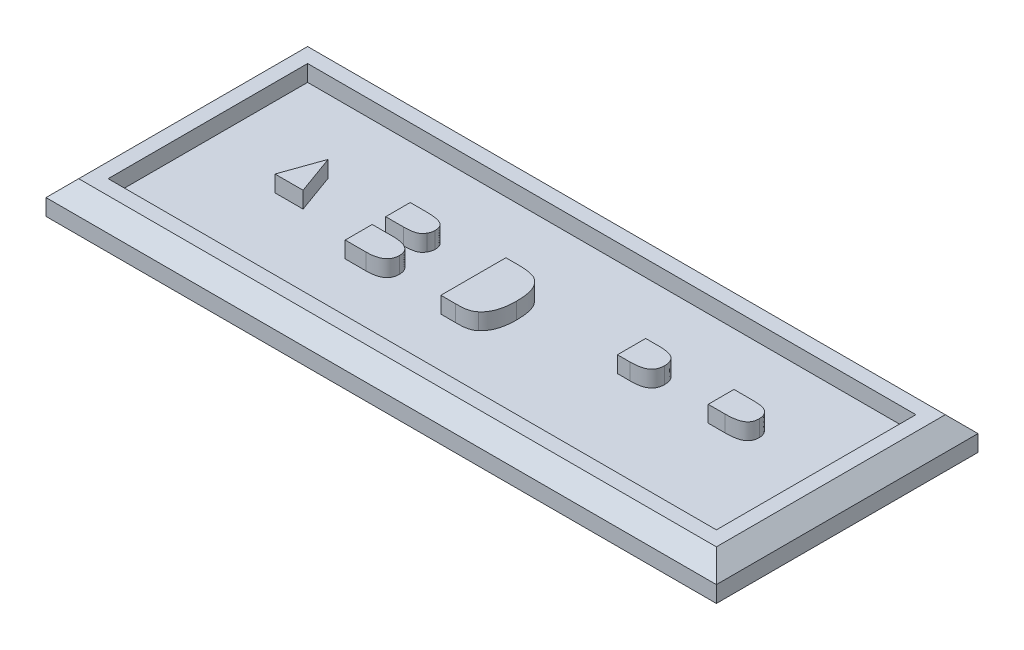
from build123d import *

# Parameters (mm, degrees)
SKETCH1_W           = 41
SKETCH1_H           = 16
BOSS_EXTRUDE1_DEPTH = 2
CHAMFER1_SIZE       = 1
SKETCH2_W           = 37.2
SKETCH2_H           = 12.2
CUT_EXTRUDE1_DEPTH  = 1
BOSS_EXTRUDE2_DEPTH = 0.1
BOSS_EXTRUDE3_DEPTH = 1
SKETCH6_W           = 37.2
SKETCH6_H           = 12.2
CUT_EXTRUDE2_DEPTH  = 1


with BuildPart() as part:
    # Sketch1 → Boss-Extrude1 (new body)
    with BuildSketch(Plane(origin=(0, 0, 0), x_dir=(1, 0, 0), z_dir=(0, 1, 0))):
        Rectangle(SKETCH1_W, SKETCH1_H)
    extrude(amount=BOSS_EXTRUDE1_DEPTH)

    # Chamfer1
    chamfer1_edges = [part.edges().sort_by_distance(p)[0] for p in [
        (20.5, 2, 0),
        (0, 2, -8),
        (-20.5, 2, 0),
        (0, 2, 8),
    ]]
    chamfer(chamfer1_edges, length=CHAMFER1_SIZE)

    # Sketch2 → Cut-Extrude1 (cut)
    with BuildSketch(Plane(origin=(0, 2, 0), x_dir=(1, 0, 0), z_dir=(0, 1, 0))):
        Rectangle(SKETCH2_W, SKETCH2_H)
    extrude(amount=-CUT_EXTRUDE1_DEPTH, mode=Mode.SUBTRACT)

    # Sketch3 → Boss-Extrude2 (add)
    with BuildSketch(Plane(origin=(0, 1, 0), x_dir=(1, 0, 0), z_dir=(0, 1, 0))):
        with BuildLine():
            Line((-11.441015625, -2.349609375), (-11.715234375, -1.65))
            Line((-11.715234375, -1.65), (-14.0484375, -1.65))
            Line((-14.0484375, -1.65), (-14.32265625, -2.36484375))
            add(Edge.make_bspline(
                [(-14.32265625, -2.36484375), (-14.347835962, -2.429152255), (-14.393986303, -2.547019345), (-14.465517251, -2.705100133), (-14.530354862, -2.829674932), (-14.59047857, -2.926424451), (-14.660607879, -2.997756493), (-14.748545347, -3.043456515), (-14.853497882, -3.070371804), (-14.929116363, -3.073387981), (-14.96953125, -3.075)],
                knots=[0, 0, 0, 0, 0.000207167, 0.000379703, 0.000520191, 0.000628424, 0.000720406, 0.000816364, 0.00092182, 0.001042887, 0.001042887, 0.001042887, 0.001042887], degree=3))
            add(Edge.make_bspline(
                [(-14.96953125, -3.075), (-15.005312309, -3.072983598), (-15.075874133, -3.069007165), (-15.177866168, -3.036727284), (-15.273080921, -2.985249355), (-15.359460508, -2.915667549), (-15.432410746, -2.833500255), (-15.485274497, -2.742148574), (-15.519177587, -2.645309748), (-15.52305102, -2.578005721), (-15.525, -2.544140625)],
                knots=[0, 0, 0, 0, 0.000107161, 0.000211326, 0.00031776, 0.000430315, 0.00054243, 0.000645342, 0.000745398, 0.00084673, 0.00084673, 0.00084673, 0.00084673], degree=3))
            add(Edge.make_bspline(
                [(-15.525, -2.544140625), (-15.523193689, -2.503741289), (-15.519483191, -2.420753523), (-15.493089704, -2.316105591), (-15.461401167, -2.225629232), (-15.432122251, -2.143573309), (-15.397345548, -2.048738896), (-15.370506217, -1.981956896), (-15.35625, -1.946484375)],
                knots=[0, 0, 0, 0, 0.000121067, 0.000248693, 0.000321699, 0.000408804, 0.000510028, 0.00062471, 0.00062471, 0.00062471, 0.00062471], degree=3))
            Line((-15.35625, -1.946484375), (-13.887890625, 1.82109375))
            add(Edge.make_bspline(
                [(-13.887890625, 1.82109375), (-13.877033183, 1.849640427), (-13.854390814, 1.909172349), (-13.81718647, 2.002041188), (-13.779422608, 2.103716802), (-13.737887875, 2.210452438), (-13.695622927, 2.317352773), (-13.648036449, 2.416388897), (-13.602120299, 2.507310579), (-13.552270206, 2.588270224), (-13.49796298, 2.661372403), (-13.43572884, 2.725938743), (-13.3651987, 2.782594974), (-13.287981265, 2.833809847), (-13.200946539, 2.874891932), (-13.104314819, 2.90434525), (-12.998298587, 2.921934285), (-12.924288276, 2.923953619), (-12.8859375, 2.925)],
                knots=[0, 0, 0, 0, 9.1624e-05, 0.000191075, 0.000300116, 0.00041698, 0.000534712, 0.000644799, 0.000746483, 0.000840145, 0.000929676, 0.001019185, 0.001108317, 0.001200627, 0.001296557, 0.001395897, 0.00150282, 0.001617813, 0.001617813, 0.001617813, 0.001617813], degree=3))
            add(Edge.make_bspline(
                [(-12.8859375, 2.925), (-12.847191426, 2.923964252), (-12.772395624, 2.921964834), (-12.665292553, 2.904219346), (-12.567931136, 2.875501695), (-12.481665511, 2.833299239), (-12.403893228, 2.783573977), (-12.333122677, 2.727829245), (-12.271563961, 2.663396877), (-12.200252444, 2.568895574), (-12.123532789, 2.440826658), (-12.059347002, 2.302613175), (-12.012806287, 2.180972039), (-11.969275082, 2.076734824), (-11.924501628, 1.957068728), (-11.892603014, 1.87264561), (-11.87578125, 1.828125)],
                knots=[0, 0, 0, 0, 0.000116163, 0.000224243, 0.000324704, 0.000419575, 0.000511251, 0.000601295, 0.000689147, 0.000777745, 0.000956013, 0.001135834, 0.001234194, 0.001346701, 0.001474671, 0.001617453, 0.001617453, 0.001617453, 0.001617453], degree=3))
            Line((-11.87578125, 1.828125), (-10.37578125, -1.91484375))
            add(Edge.make_bspline(
                [(-10.37578125, -1.91484375), (-10.362069188, -1.94919831), (-10.335664466, -2.015353397), (-10.298319026, -2.110858221), (-10.270475505, -2.200435562), (-10.242779562, -2.281190367), (-10.225096723, -2.35601766), (-10.210418027, -2.422642639), (-10.201346416, -2.482167939), (-10.200431427, -2.519504684), (-10.2, -2.537109375)],
                knots=[0, 0, 0, 0, 0.000110982, 0.000213714, 0.000307471, 0.000392341, 0.000469649, 0.00053791, 0.000597075, 0.000649862, 0.000649862, 0.000649862, 0.000649862], degree=3))
            add(Edge.make_bspline(
                [(-10.2, -2.537109375), (-10.202155142, -2.570132184), (-10.206480473, -2.636408348), (-10.238168464, -2.733668106), (-10.293183658, -2.82468516), (-10.364464071, -2.910029077), (-10.450232948, -2.983212519), (-10.54839153, -3.036396381), (-10.654957368, -3.069176662), (-10.729456816, -3.07304225), (-10.7671875, -3.075)],
                knots=[0, 0, 0, 0, 9.9001e-05, 0.000198693, 0.000303207, 0.00041634, 0.000531124, 0.000639146, 0.000749259, 0.000862252, 0.000862252, 0.000862252, 0.000862252], degree=3))
            add(Edge.make_bspline(
                [(-10.7671875, -3.075), (-10.810045817, -3.073116816), (-10.890793668, -3.069568774), (-11.002453245, -3.033539946), (-11.093956784, -2.974673834), (-11.15863903, -2.911722548), (-11.203137979, -2.848941962), (-11.238148472, -2.791272681), (-11.274323764, -2.723100446), (-11.322497594, -2.62112411), (-11.37672123, -2.494818059), (-11.420622538, -2.395667095), (-11.441015625, -2.349609375)],
                knots=[0, 0, 0, 0, 0.000128271, 0.000241671, 0.000347009, 0.00045225, 0.000510148, 0.000577477, 0.000654545, 0.000741556, 0.000915752, 0.001066865, 0.001066865, 0.001066865, 0.001066865], degree=3))
        make_face()
        Polygon((-13.74375, -0.75), (-12.028125, -0.75), (-12.894140625, 1.65), align=None, mode=Mode.SUBTRACT)
        with BuildLine():
            Line((-6.75703125, -3), (-8.5171875, -3))
            add(Edge.make_bspline(
                [(-8.5171875, -3), (-8.548066158, -2.999684683), (-8.607211026, -2.999080726), (-8.692644647, -2.990770966), (-8.770947545, -2.976754729), (-8.842771247, -2.958217792), (-8.908089191, -2.93471954), (-8.96692833, -2.9061107), (-9.017782509, -2.869904795), (-9.07875055, -2.816360555), (-9.140301939, -2.729140438), (-9.189624937, -2.601657903), (-9.219877565, -2.450216486), (-9.223214212, -2.341173041), (-9.225, -2.2828125)],
                knots=[0, 0, 0, 0, 9.2608e-05, 0.000177381, 0.000257146, 0.000331048, 0.00039963, 0.00046514, 0.000526583, 0.000586337, 0.000707992, 0.000842042, 0.000993957, 0.001168885, 0.001168885, 0.001168885, 0.001168885], degree=3))
            Line((-9.225, -2.2828125), (-9.225, 2.0578125))
            add(Edge.make_bspline(
                [(-9.225, 2.0578125), (-9.223375416, 2.117371055), (-9.220355101, 2.228098226), (-9.188552092, 2.381042192), (-9.138305638, 2.508895247), (-9.062752389, 2.611877256), (-8.960932817, 2.687796753), (-8.834312538, 2.738830555), (-8.683927793, 2.770066267), (-8.575170639, 2.773284318), (-8.5171875, 2.775)],
                knots=[0, 0, 0, 0, 0.000178437, 0.000331738, 0.000466233, 0.00058764, 0.000709751, 0.000842085, 0.000994239, 0.001167997, 0.001167997, 0.001167997, 0.001167997], degree=3))
            Line((-8.5171875, 2.775), (-6.6515625, 2.775))
            add(Edge.make_bspline(
                [(-6.6515625, 2.775), (-6.585147608, 2.774247249), (-6.456546362, 2.772789674), (-6.270794249, 2.763868156), (-6.098739867, 2.74744078), (-5.939206601, 2.724758831), (-5.790298563, 2.691685935), (-5.649474707, 2.649197945), (-5.517714172, 2.591062773), (-5.435171158, 2.544064871), (-5.394140625, 2.520703125)],
                knots=[0, 0, 0, 0, 0.00019925, 0.000385814, 0.000557692, 0.000717622, 0.00086888, 0.001014918, 0.00115818, 0.001299778, 0.001299778, 0.001299778, 0.001299778], degree=3))
            add(Edge.make_bspline(
                [(-5.394140625, 2.520703125), (-5.360161211, 2.499396475), (-5.29220561, 2.456785199), (-5.197222519, 2.382645993), (-5.108971786, 2.299601488), (-5.026233579, 2.210306513), (-4.95099385, 2.114129902), (-4.885128336, 2.012316969), (-4.83023231, 1.904654916), (-4.783065612, 1.793232088), (-4.745153453, 1.677770503), (-4.720148205, 1.558227489), (-4.702342929, 1.436082227), (-4.701045751, 1.353191284), (-4.700390625, 1.311328125)],
                knots=[0, 0, 0, 0, 0.000120264, 0.000240517, 0.000360741, 0.000483481, 0.000605379, 0.000726627, 0.000846651, 0.000967445, 0.001089371, 0.001210505, 0.00133348, 0.001458958, 0.001458958, 0.001458958, 0.001458958], degree=3))
            add(Edge.make_bspline(
                [(-4.700390625, 1.311328125), (-4.702988671, 1.240796002), (-4.708044042, 1.103552116), (-4.750406113, 0.905273758), (-4.818338805, 0.720970725), (-4.915852756, 0.551862405), (-5.040552639, 0.397345857), (-5.194337126, 0.260072678), (-5.37373492, 0.13565648), (-5.50764742, 0.068658714), (-5.576953125, 0.033984375)],
                knots=[0, 0, 0, 0, 0.000211406, 0.000411361, 0.000605302, 0.000798476, 0.000994306, 0.001198394, 0.001414886, 0.001647125, 0.001647125, 0.001647125, 0.001647125], degree=3))
            add(Edge.make_bspline(
                [(-5.576953125, 0.033984375), (-5.530273502, 0.01850607), (-5.439172939, -0.011701592), (-5.308710293, -0.065060268), (-5.186483504, -0.121876895), (-5.073507124, -0.185143227), (-4.970263496, -0.254875067), (-4.874609675, -0.328273429), (-4.789067069, -0.408268175), (-4.712116337, -0.493263322), (-4.644210619, -0.58342165), (-4.584823142, -0.678896049), (-4.536232473, -0.780262552), (-4.493934136, -0.885899675), (-4.464826814, -0.998402007), (-4.440274592, -1.115100833), (-4.428038837, -1.23763197), (-4.42602398, -1.320682894), (-4.425, -1.362890625)],
                knots=[0, 0, 0, 0, 0.000147498, 0.000287859, 0.000422584, 0.000551661, 0.000675819, 0.000796071, 0.000912983, 0.001026655, 0.001139624, 0.001251174, 0.001363332, 0.001476495, 0.001591917, 0.001711426, 0.00183398, 0.00196063, 0.00196063, 0.00196063, 0.00196063], degree=3))
            add(Edge.make_bspline(
                [(-4.425, -1.362890625), (-4.427626881, -1.44089384), (-4.432814111, -1.594924682), (-4.483110744, -1.819042589), (-4.561780312, -2.031773243), (-4.672429347, -2.228892641), (-4.807833827, -2.408638341), (-4.967607701, -2.564839815), (-5.150016922, -2.696405243), (-5.285579599, -2.761004415), (-5.354296875, -2.79375)],
                knots=[0, 0, 0, 0, 0.0002337, 0.000461481, 0.00068546, 0.000912081, 0.001137084, 0.001358345, 0.001580123, 0.001808113, 0.001808113, 0.001808113, 0.001808113], degree=3))
            add(Edge.make_bspline(
                [(-5.354296875, -2.79375), (-5.399754504, -2.812000974), (-5.492589121, -2.849273534), (-5.639572751, -2.893494252), (-5.796443624, -2.92800838), (-5.963359802, -2.956604003), (-6.142283634, -2.975665677), (-6.334601684, -2.989341746), (-6.540910731, -2.999407091), (-6.683580759, -2.999798494), (-6.75703125, -3)],
                knots=[0, 0, 0, 0, 0.000146901, 0.000300005, 0.00045978, 0.000628546, 0.000807782, 0.000999314, 0.001206948, 0.001427273, 0.001427273, 0.001427273, 0.001427273], degree=3))
        make_face()
        with BuildLine():
            Line((-6.866015625, -0.45), (-8.1, -0.45))
            Line((-8.1, -0.45), (-8.1, -2.1))
            Line((-8.1, -2.1), (-6.826171875, -2.1))
            add(Edge.make_bspline(
                [(-6.826171875, -2.1), (-6.777720139, -2.099260062), (-6.683848213, -2.097826483), (-6.547668719, -2.088674975), (-6.420786989, -2.072623285), (-6.303057731, -2.048918848), (-6.19447374, -2.020075741), (-6.094628476, -1.985453955), (-6.005533659, -1.941617105), (-5.925267164, -1.89244311), (-5.853888708, -1.837197568), (-5.792861506, -1.774583052), (-5.739940848, -1.705833559), (-5.698576331, -1.629501969), (-5.664668864, -1.547186893), (-5.641976186, -1.458024455), (-5.62748436, -1.362583512), (-5.625841839, -1.296930349), (-5.625, -1.26328125)],
                knots=[0, 0, 0, 0, 0.000145355, 0.000281615, 0.000409237, 0.000528745, 0.000641599, 0.000746126, 0.000845182, 0.000938844, 0.001028161, 0.001115172, 0.001200486, 0.00128756, 0.001374823, 0.001466918, 0.001562876, 0.001663766, 0.001663766, 0.001663766, 0.001663766], degree=3))
            add(Edge.make_bspline(
                [(-5.625, -1.26328125), (-5.625704015, -1.228834593), (-5.627071551, -1.161922567), (-5.64318541, -1.065837099), (-5.666139932, -0.976233925), (-5.699962563, -0.893909), (-5.744868844, -0.819385402), (-5.800071385, -0.753075959), (-5.863123559, -0.692676281), (-5.937347526, -0.641318834), (-6.019753136, -0.594787172), (-6.113258959, -0.557290203), (-6.215033472, -0.522598461), (-6.327010403, -0.496378925), (-6.447921802, -0.475420915), (-6.578556708, -0.459968142), (-6.71905487, -0.452548971), (-6.816009173, -0.45086734), (-6.866015625, -0.45)],
                knots=[0, 0, 0, 0, 0.000103231, 0.000200525, 0.000291487, 0.00038028, 0.000466498, 0.000551425, 0.000638467, 0.000727561, 0.000821464, 0.000921795, 0.001029263, 0.001143807, 0.00126634, 0.001397307, 0.001538171, 0.001688212, 0.001688212, 0.001688212, 0.001688212], degree=3))
        make_face(mode=Mode.SUBTRACT)
        with BuildLine():
            Line((-8.1, 1.875), (-8.1, 0.375))
            Line((-8.1, 0.375), (-7.013671875, 0.375))
            add(Edge.make_bspline(
                [(-7.013671875, 0.375), (-6.944100141, 0.375547166), (-6.812936635, 0.376578738), (-6.628933086, 0.393268924), (-6.469619665, 0.418052621), (-6.332356548, 0.453074997), (-6.214905261, 0.506003437), (-6.112804428, 0.575815208), (-6.027108057, 0.667068455), (-5.982808737, 0.73822396), (-5.96015625, 0.774609375)],
                knots=[0, 0, 0, 0, 0.000208646, 0.000393361, 0.000553651, 0.000692096, 0.000816916, 0.000938169, 0.001060853, 0.001189236, 0.001189236, 0.001189236, 0.001189236], degree=3))
            add(Edge.make_bspline(
                [(-5.96015625, 0.774609375), (-5.944350806, 0.802692653), (-5.912693315, 0.858942014), (-5.882526595, 0.951249941), (-5.860618747, 1.047408065), (-5.859019005, 1.113538601), (-5.858203125, 1.147265625)],
                knots=[0, 0, 0, 0, 9.6443e-05, 0.000193171, 0.000290161, 0.000391112, 0.000391112, 0.000391112, 0.000391112], degree=3))
            add(Edge.make_bspline(
                [(-5.858203125, 1.147265625), (-5.858880214, 1.182490436), (-5.860173872, 1.249791616), (-5.876075458, 1.346082984), (-5.900230553, 1.433209508), (-5.934048828, 1.511937877), (-5.979566689, 1.580991986), (-6.034574613, 1.641305314), (-6.100700545, 1.690905997), (-6.175754603, 1.732386596), (-6.260921832, 1.76555212), (-6.355786594, 1.794829715), (-6.460513226, 1.82078131), (-6.576238707, 1.839662661), (-6.701559152, 1.856920013), (-6.83740279, 1.866152343), (-6.983504193, 1.873942321), (-7.084361917, 1.874638567), (-7.13671875, 1.875)],
                knots=[0, 0, 0, 0, 0.000105573, 0.000201709, 0.000291852, 0.000376333, 0.000457591, 0.000538865, 0.000619962, 0.000704418, 0.00079538, 0.000893601, 0.001002175, 0.001118734, 0.001245194, 0.00138154, 0.001527022, 0.001684071, 0.001684071, 0.001684071, 0.001684071], degree=3))
            Line((-7.13671875, 1.875), (-8.1, 1.875))
        make_face(mode=Mode.SUBTRACT)
        with BuildLine():
            Line((-2.6859375, 2.775), (-1.147265625, 2.775))
            add(Edge.make_bspline(
                [(-1.147265625, 2.775), (-1.050750895, 2.77361917), (-0.864535134, 2.770954993), (-0.595997762, 2.751570127), (-0.349102986, 2.717452462), (-0.120663099, 2.671840852), (0.092500353, 2.605420148), (0.294335668, 2.517397132), (0.486016839, 2.404286593), (0.60295242, 2.311947915), (0.662109375, 2.265234375)],
                knots=[0, 0, 0, 0, 0.000289539, 0.000558636, 0.000807066, 0.001036896, 0.001256688, 0.001475506, 0.001696179, 0.001922117, 0.001922117, 0.001922117, 0.001922117], degree=3))
            add(Edge.make_bspline(
                [(0.662109375, 2.265234375), (0.699204557, 2.23204259), (0.773360626, 2.165689706), (0.877526546, 2.059236928), (0.97420917, 1.946074816), (1.063080409, 1.826413034), (1.145281744, 1.700806739), (1.220533689, 1.569000172), (1.28895067, 1.430736631), (1.347729443, 1.284821053), (1.402581568, 1.134012825), (1.447237326, 0.976216153), (1.488225883, 0.813191248), (1.518697841, 0.642687976), (1.545203145, 0.466575533), (1.562176311, 0.283861789), (1.573097822, 0.095057741), (1.574358547, -0.033186992), (1.575, -0.0984375)],
                knots=[0, 0, 0, 0, 0.000149303, 0.000298467, 0.000446421, 0.000595484, 0.000745324, 0.000896491, 0.001050574, 0.001207697, 0.001368192, 0.001531739, 0.001699432, 0.001872275, 0.002051096, 0.002233585, 0.002422552, 0.002618286, 0.002618286, 0.002618286, 0.002618286], degree=3))
            add(Edge.make_bspline(
                [(1.575, -0.0984375), (1.573794855, -0.184006161), (1.571442807, -0.351008177), (1.555405103, -0.596376388), (1.525887303, -0.829812399), (1.486384251, -1.052573716), (1.435093541, -1.264175052), (1.370915117, -1.464887332), (1.293061527, -1.654819682), (1.202701995, -1.834095171), (1.100629294, -2.004458553), (0.983405175, -2.163815899), (0.855141018, -2.31644177), (0.758700791, -2.408659192), (0.71015625, -2.455078125)],
                knots=[0, 0, 0, 0, 0.000256708, 0.000501009, 0.000737208, 0.000962248, 0.001179396, 0.001389897, 0.001593806, 0.001794529, 0.001991686, 0.002188816, 0.002387486, 0.002588847, 0.002588847, 0.002588847, 0.002588847], degree=3))
            add(Edge.make_bspline(
                [(0.71015625, -2.455078125), (0.670808323, -2.487756238), (0.59276456, -2.552570909), (0.46729574, -2.638086397), (0.337301324, -2.714845461), (0.200908362, -2.780164108), (0.059765152, -2.836294246), (-0.085968828, -2.884905991), (-0.237194539, -2.923298904), (-0.39419838, -2.95267784), (-0.558630516, -2.973282528), (-0.732193291, -2.98840301), (-0.916303006, -2.997859007), (-1.042566688, -2.999273465), (-1.107421875, -3)],
                knots=[0, 0, 0, 0, 0.000153368, 0.000304194, 0.000454934, 0.000605883, 0.000757341, 0.000910391, 0.001066431, 0.001225019, 0.00138927, 0.001563375, 0.001747599, 0.001942162, 0.001942162, 0.001942162, 0.001942162], degree=3))
            Line((-1.107421875, -3), (-2.633203125, -3))
            add(Edge.make_bspline(
                [(-2.633203125, -3), (-2.683293312, -2.999225047), (-2.77723658, -2.997771636), (-2.908251776, -2.978207976), (-3.020827368, -2.951188051), (-3.114131747, -2.908026317), (-3.189319084, -2.852952048), (-3.250458451, -2.788830509), (-3.297101361, -2.714732595), (-3.329030277, -2.629666887), (-3.348444949, -2.533803398), (-3.363873799, -2.426199575), (-3.372929583, -2.305618442), (-3.374287517, -2.220717744), (-3.375, -2.176171875)],
                knots=[0, 0, 0, 0, 0.000150114, 0.000281537, 0.000396655, 0.000496265, 0.000587679, 0.000674721, 0.000760557, 0.000848479, 0.000945716, 0.001053439, 0.001174506, 0.001308146, 0.001308146, 0.001308146, 0.001308146], degree=3))
            Line((-3.375, -2.176171875), (-3.375, 2.0578125))
            add(Edge.make_bspline(
                [(-3.375, 2.0578125), (-3.373208148, 2.11656741), (-3.369858826, 2.226391877), (-3.339719242, 2.378565117), (-3.29070443, 2.506457745), (-3.21653605, 2.608767051), (-3.117551938, 2.685414072), (-2.995036312, 2.73910011), (-2.847982054, 2.769962347), (-2.742343971, 2.773246431), (-2.6859375, 2.775)],
                knots=[0, 0, 0, 0, 0.000176097, 0.000329161, 0.000463211, 0.00058392, 0.00070325, 0.000834374, 0.000981947, 0.001151026, 0.001151026, 0.001151026, 0.001151026], degree=3))
        make_face()
        with BuildLine():
            Line((-2.25, 1.875), (-2.25, -2.1))
            Line((-2.25, -2.1), (-1.348828125, -2.1))
            add(Edge.make_bspline(
                [(-1.348828125, -2.1), (-1.301952959, -2.099682321), (-1.213665465, -2.099083984), (-1.089019885, -2.097143205), (-0.980770626, -2.092606267), (-0.855941872, -2.083780861), (-0.707361822, -2.059429954), (-0.56212929, -2.017298838), (-0.447473415, -1.971414286), (-0.366083943, -1.929742568), (-0.290655674, -1.881024345), (-0.24534936, -1.843436463), (-0.22265625, -1.824609375)],
                knots=[0, 0, 0, 0, 0.00014063, 0.000264871, 0.000373956, 0.000465632, 0.000640179, 0.000824491, 0.000918065, 0.001010309, 0.001098395, 0.001186792, 0.001186792, 0.001186792, 0.001186792], degree=3))
            add(Edge.make_bspline(
                [(-0.22265625, -1.824609375), (-0.174181295, -1.780388245), (-0.076131606, -1.690942717), (0.043709489, -1.526438596), (0.147596825, -1.342616732), (0.232242795, -1.135553307), (0.295344373, -0.905543722), (0.341950582, -0.653901784), (0.370143723, -0.379544752), (0.373339938, -0.189131774), (0.375, -0.090234375)],
                knots=[0, 0, 0, 0, 0.000196404, 0.000397263, 0.000607156, 0.000828913, 0.001066345, 0.001321469, 0.001595961, 0.001892593, 0.001892593, 0.001892593, 0.001892593], degree=3))
            add(Edge.make_bspline(
                [(0.375, -0.090234375), (0.374613805, -0.020283582), (0.373864422, 0.115450693), (0.359892665, 0.31202576), (0.341518407, 0.495370092), (0.311251991, 0.664511381), (0.276435894, 0.820933105), (0.230056316, 0.962771279), (0.178119695, 1.092191471), (0.115207656, 1.207119841), (0.046982556, 1.310390824), (-0.024766633, 1.403586359), (-0.099960412, 1.487051335), (-0.178317438, 1.561791416), (-0.262144451, 1.625048686), (-0.349182623, 1.679209337), (-0.439819376, 1.724771952), (-0.569492844, 1.769364728), (-0.742809226, 1.811835322), (-0.965630986, 1.849495527), (-1.208538375, 1.871555399), (-1.377297566, 1.873823428), (-1.46484375, 1.875)],
                knots=[0, 0, 0, 0, 0.000209795, 0.000407092, 0.000590986, 0.000762261, 0.000922298, 0.001071278, 0.00120947, 0.001340033, 0.001463542, 0.001580507, 0.001692523, 0.001800298, 0.001904831, 0.002006939, 0.002107564, 0.002208386, 0.002417574, 0.002642211, 0.002885809, 0.003148403, 0.003148403, 0.003148403, 0.003148403], degree=3))
            Line((-1.46484375, 1.875), (-2.25, 1.875))
        make_face(mode=Mode.SUBTRACT)
        with BuildLine():
            Line((2.625, -2.358984375), (2.625, 2.2125))
            add(Edge.make_bspline(
                [(2.625, 2.2125), (2.626372257, 2.268534342), (2.628947099, 2.373674747), (2.65887973, 2.520292536), (2.705191012, 2.646298707), (2.775330907, 2.747864159), (2.858882217, 2.828196162), (2.956909337, 2.884115843), (3.065500905, 2.920066505), (3.142287861, 2.923328335), (3.181640625, 2.925)],
                knots=[0, 0, 0, 0, 0.00016784, 0.000314928, 0.000447023, 0.000567612, 0.000682013, 0.000791757, 0.000903681, 0.001021343, 0.001021343, 0.001021343, 0.001021343], degree=3))
            add(Edge.make_bspline(
                [(3.181640625, 2.925), (3.222162859, 2.923361853), (3.300865244, 2.920180241), (3.41214605, 2.88414904), (3.511943317, 2.82855475), (3.597693577, 2.74913551), (3.668158131, 2.647775576), (3.716893344, 2.522277833), (3.745841861, 2.374760553), (3.748554739, 2.268897544), (3.75, 2.2125)],
                knots=[0, 0, 0, 0, 0.000121163, 0.000235323, 0.000347101, 0.000461561, 0.000582815, 0.000714253, 0.000862489, 0.0010315, 0.0010315, 0.0010315, 0.0010315], degree=3))
            Line((3.75, 2.2125), (3.75, -2.358984375))
            add(Edge.make_bspline(
                [(3.75, -2.358984375), (3.748566282, -2.415383127), (3.745875072, -2.521248402), (3.716714134, -2.669108291), (3.668099781, -2.795271696), (3.598139431, -2.897981928), (3.511533961, -2.977024753), (3.412747746, -3.034810993), (3.300519327, -3.068262311), (3.222095717, -3.072707127), (3.181640625, -3.075)],
                knots=[0, 0, 0, 0, 0.00016901, 0.000317247, 0.000449772, 0.00057199, 0.000686451, 0.00079881, 0.000912627, 0.001033898, 0.001033898, 0.001033898, 0.001033898], degree=3))
            add(Edge.make_bspline(
                [(3.181640625, -3.075), (3.142749904, -3.07267064), (3.067019935, -3.068134792), (2.958513966, -3.034840225), (2.862545505, -2.975966407), (2.777305392, -2.89685328), (2.706176655, -2.794152097), (2.660632263, -2.666937475), (2.628451723, -2.520345529), (2.626199442, -2.415055894), (2.625, -2.358984375)],
                knots=[0, 0, 0, 0, 0.000116606, 0.000227061, 0.000336391, 0.000451647, 0.000573865, 0.000707052, 0.000854378, 0.001022218, 0.001022218, 0.001022218, 0.001022218], degree=3))
        make_face()
        with BuildLine():
            Line((7.359375, -0.75), (6.3, -0.75))
            Line((6.3, -0.75), (6.3, -2.368359375))
            add(Edge.make_bspline(
                [(6.3, -2.368359375), (6.29865037, -2.422834651), (6.296091572, -2.526115714), (6.2652422, -2.670183826), (6.216669575, -2.795106489), (6.145364996, -2.896517112), (6.059997751, -2.976407479), (5.963163888, -3.034522007), (5.854499391, -3.068193031), (5.77874633, -3.0726904), (5.73984375, -3.075)],
                knots=[0, 0, 0, 0, 0.00016316, 0.00030934, 0.000439692, 0.000562577, 0.000677832, 0.000788169, 0.000898624, 0.00101523, 0.00101523, 0.00101523, 0.00101523], degree=3))
            add(Edge.make_bspline(
                [(5.73984375, -3.075), (5.699400293, -3.072687248), (5.620999236, -3.068203896), (5.508937943, -3.035123568), (5.4109881, -2.976607828), (5.324815484, -2.898467898), (5.255941764, -2.796656723), (5.208699533, -2.672816611), (5.179213967, -2.529502753), (5.17645619, -2.427112203), (5.175, -2.373046875)],
                knots=[0, 0, 0, 0, 0.000121271, 0.000235087, 0.000346434, 0.000460895, 0.000581484, 0.000711398, 0.00085619, 0.00101818, 0.00101818, 0.00101818, 0.00101818], degree=3))
            Line((5.175, -2.373046875), (5.175, 2.061328125))
            add(Edge.make_bspline(
                [(5.175, 2.061328125), (5.175326, 2.09220632), (5.175954525, 2.15173923), (5.184245402, 2.237947887), (5.19814518, 2.31705589), (5.216762086, 2.38978201), (5.241059702, 2.455040586), (5.270780076, 2.513726999), (5.305784318, 2.565747457), (5.361797587, 2.626083745), (5.449096695, 2.689250897), (5.577875048, 2.739853278), (5.731051886, 2.76986248), (5.841252832, 2.773205835), (5.900390625, 2.775)],
                knots=[0, 0, 0, 0, 9.2608e-05, 0.000178547, 0.000259466, 0.000333368, 0.000403456, 0.00046792, 0.000530327, 0.000590869, 0.000714161, 0.000849739, 0.001002802, 0.00118007, 0.00118007, 0.00118007, 0.00118007], degree=3))
            Line((5.900390625, 2.775), (7.369921875, 2.775))
            add(Edge.make_bspline(
                [(7.369921875, 2.775), (7.422664023, 2.775010091), (7.525059934, 2.775029682), (7.67389829, 2.768466252), (7.813367698, 2.760337506), (7.943654943, 2.750601935), (8.064431442, 2.735243653), (8.175705348, 2.716216263), (8.278076971, 2.696041062), (8.34228087, 2.678119244), (8.373046875, 2.66953125)],
                knots=[0, 0, 0, 0, 0.000158207, 0.000307151, 0.000446845, 0.00057735, 0.000699011, 0.000811907, 0.000916019, 0.001011812, 0.001011812, 0.001011812, 0.001011812], degree=3))
            add(Edge.make_bspline(
                [(8.373046875, 2.66953125), (8.431373386, 2.651775877), (8.546114862, 2.61684703), (8.707380779, 2.541218339), (8.858062265, 2.452337636), (8.994731548, 2.345234583), (9.11799016, 2.224738583), (9.225960776, 2.090733108), (9.317803465, 1.943647039), (9.392092467, 1.783400112), (9.452798531, 1.613008843), (9.494072303, 1.431259277), (9.520933822, 1.239476645), (9.523624188, 1.107907437), (9.525, 1.040625)],
                knots=[0, 0, 0, 0, 0.000182696, 0.000359405, 0.000532846, 0.000706545, 0.00087891, 0.001048933, 0.001221596, 0.001397737, 0.001577863, 0.001763197, 0.001955944, 0.002157674, 0.002157674, 0.002157674, 0.002157674], degree=3))
            add(Edge.make_bspline(
                [(9.525, 1.040625), (9.523639944, 0.969441406), (9.520992452, 0.830875104), (9.494270667, 0.62970649), (9.453125864, 0.441306934), (9.39297871, 0.266296959), (9.315551283, 0.104972014), (9.220902953, -0.042832746), (9.109921711, -0.177754192), (8.98145365, -0.298843797), (8.836103572, -0.405856207), (8.674464805, -0.499348035), (8.494831071, -0.575599183), (8.299940545, -0.640791532), (8.087750438, -0.688685124), (7.860062704, -0.725424075), (7.615229659, -0.746190147), (7.446522436, -0.748702314), (7.359375, -0.75)],
                knots=[0, 0, 0, 0, 0.000213439, 0.000415481, 0.000607669, 0.000791115, 0.000969321, 0.001143237, 0.001316389, 0.001492131, 0.001671432, 0.001856759, 0.002050951, 0.002255881, 0.002472485, 0.002702713, 0.002947374, 0.003208797, 0.003208797, 0.003208797, 0.003208797], degree=3))
        make_face()
        with BuildLine():
            Line((7.079296875, 1.875), (6.3, 1.875))
            Line((6.3, 1.875), (6.3, 0.15))
            Line((6.3, 0.15), (7.079296875, 0.15))
            add(Edge.make_bspline(
                [(7.079296875, 0.15), (7.144552787, 0.15127628), (7.269782601, 0.153725533), (7.449698587, 0.168015061), (7.612530249, 0.195256242), (7.759544167, 0.230373954), (7.890182322, 0.279196987), (8.004009077, 0.343320349), (8.102772374, 0.419341397), (8.183904798, 0.510414659), (8.249107629, 0.615297641), (8.292297466, 0.736407096), (8.320221021, 0.87139033), (8.323355598, 0.966251421), (8.325, 1.016015625)],
                knots=[0, 0, 0, 0, 0.000195791, 0.000375734, 0.000540839, 0.000690624, 0.000828607, 0.000957684, 0.001081226, 0.001200734, 0.001321727, 0.001449284, 0.001584421, 0.001733544, 0.001733544, 0.001733544, 0.001733544], degree=3))
            add(Edge.make_bspline(
                [(8.325, 1.016015625), (8.322476825, 1.075677694), (8.317613712, 1.190669086), (8.275176343, 1.354356194), (8.207071184, 1.502576282), (8.137949335, 1.583770884), (8.103515625, 1.62421875)],
                knots=[0, 0, 0, 0, 0.000178679, 0.000344383, 0.000504248, 0.000662941, 0.000662941, 0.000662941, 0.000662941], degree=3))
            add(Edge.make_bspline(
                [(8.103515625, 1.62421875), (8.080667048, 1.644517036), (8.032632313, 1.687190277), (7.944137357, 1.738697863), (7.83868375, 1.779103706), (7.718881299, 1.816552442), (7.581921001, 1.841884672), (7.429030444, 1.86204481), (7.259544379, 1.873391351), (7.141031062, 1.874449043), (7.079296875, 1.875)],
                knots=[0, 0, 0, 0, 9.1526e-05, 0.000192417, 0.000304923, 0.000429852, 0.000568436, 0.000722077, 0.000892403, 0.001077592, 0.001077592, 0.001077592, 0.001077592], degree=3))
        make_face(mode=Mode.SUBTRACT)
        with BuildLine():
            Line((12.10546875, -0.525), (11.7, -0.525))
            Line((11.7, -0.525), (11.7, -2.3671875))
            add(Edge.make_bspline(
                [(11.7, -2.3671875), (11.698572444, -2.423972464), (11.695901407, -2.530220255), (11.666941387, -2.678184043), (11.618204871, -2.802976511), (11.549336018, -2.90393262), (11.463990524, -2.980416024), (11.366621919, -3.035790544), (11.256882965, -3.069690448), (11.179539779, -3.073199166), (11.13984375, -3.075)],
                knots=[0, 0, 0, 0, 0.00017018, 0.000318417, 0.000449855, 0.000569478, 0.000681495, 0.000790655, 0.000903351, 0.001022179, 0.001022179, 0.001022179, 0.001022179], degree=3))
            add(Edge.make_bspline(
                [(11.13984375, -3.075), (11.097419425, -3.072847061), (11.015769314, -3.068703501), (10.900783826, -3.034322246), (10.801478575, -2.976118471), (10.717621239, -2.896018404), (10.65254807, -2.792486711), (10.60773047, -2.667792628), (10.579406988, -2.52313387), (10.576526661, -2.419678338), (10.575, -2.36484375)],
                knots=[0, 0, 0, 0, 0.000127104, 0.000244625, 0.000355972, 0.000469523, 0.000589151, 0.000719314, 0.000865023, 0.001029353, 0.001029353, 0.001029353, 0.001029353], degree=3))
            Line((10.575, -2.36484375), (10.575, 2.061328125))
            add(Edge.make_bspline(
                [(10.575, 2.061328125), (10.576717433, 2.119700782), (10.579939967, 2.229229306), (10.611185323, 2.380758993), (10.661991643, 2.508002941), (10.737132998, 2.610363541), (10.838271675, 2.686760864), (10.963899667, 2.7389316), (11.114124036, 2.770093303), (11.22249019, 2.773289797), (11.28046875, 2.775)],
                knots=[0, 0, 0, 0, 0.000174928, 0.000328228, 0.000461642, 0.000583049, 0.000704229, 0.000837023, 0.000988032, 0.001161789, 0.001161789, 0.001161789, 0.001161789], degree=3))
            Line((11.28046875, 2.775), (13.15078125, 2.775))
            add(Edge.make_bspline(
                [(13.15078125, 2.775), (13.21289178, 2.774430966), (13.332453914, 2.773335582), (13.50526269, 2.768342035), (13.663881101, 2.75614996), (13.81016602, 2.74123347), (13.946041381, 2.721250507), (14.073420863, 2.689764053), (14.19478395, 2.652351796), (14.27099611, 2.618341), (14.30859375, 2.6015625)],
                knots=[0, 0, 0, 0, 0.000186343, 0.000358708, 0.000518513, 0.000663457, 0.000799863, 0.000930042, 0.001056788, 0.001180198, 0.001180198, 0.001180198, 0.001180198], degree=3))
            add(Edge.make_bspline(
                [(14.30859375, 2.6015625), (14.353582506, 2.581367881), (14.443038172, 2.541212889), (14.569212555, 2.464904163), (14.687701522, 2.377402182), (14.796574168, 2.27704196), (14.896674058, 2.168008704), (14.981985979, 2.047080162), (15.056486904, 1.919163218), (15.117376597, 1.782717936), (15.164813632, 1.640079538), (15.200936101, 1.492909041), (15.220597728, 1.341161353), (15.223525056, 1.23872317), (15.225, 1.187109375)],
                knots=[0, 0, 0, 0, 0.000147824, 0.000293932, 0.000441356, 0.000589003, 0.000737517, 0.000884507, 0.001032042, 0.001181013, 0.001331839, 0.001482483, 0.001634962, 0.00178981, 0.00178981, 0.00178981, 0.00178981], degree=3))
            add(Edge.make_bspline(
                [(15.225, 1.187109375), (15.223956718, 1.134710524), (15.221918474, 1.03233966), (15.203643115, 0.883074123), (15.175810889, 0.741460512), (15.136781622, 0.607451297), (15.082764636, 0.482536927), (15.020094294, 0.36509985), (14.945217241, 0.255719379), (14.858281951, 0.154807046), (14.758988282, 0.062219159), (14.648880411, -0.024102067), (14.527204838, -0.103775569), (14.392676981, -0.174943092), (14.246708981, -0.239839169), (14.088394073, -0.296014466), (13.919210071, -0.349045565), (13.801009462, -0.37547388), (13.740234375, -0.3890625)],
                knots=[0, 0, 0, 0, 0.000157141, 0.000307003, 0.000450413, 0.000589822, 0.000724771, 0.000857953, 0.000988621, 0.001121576, 0.001256708, 0.001395257, 0.001540871, 0.001692388, 0.001851353, 0.002019655, 0.002196107, 0.002382851, 0.002382851, 0.002382851, 0.002382851], degree=3))
            add(Edge.make_bspline(
                [(13.740234375, -0.3890625), (13.79292272, -0.418377195), (13.900356973, -0.47815137), (14.051545518, -0.592267678), (14.200943792, -0.723024412), (14.342711005, -0.874546899), (14.480454086, -1.036097603), (14.613490676, -1.203536232), (14.737564197, -1.376988341), (14.851914813, -1.553777857), (14.957696081, -1.727533907), (15.051828616, -1.895064714), (15.132527888, -2.054490042), (15.201102073, -2.202550151), (15.255725211, -2.334695195), (15.29464115, -2.446540109), (15.32078646, -2.535205559), (15.325961842, -2.587787791), (15.328125, -2.609765625)],
                knots=[0, 0, 0, 0, 0.000180685, 0.000368427, 0.000566862, 0.000775738, 0.000990169, 0.001203753, 0.001417086, 0.001629661, 0.00183526, 0.00202728, 0.002205994, 0.002371162, 0.002516748, 0.002634602, 0.002726696, 0.002792832, 0.002792832, 0.002792832, 0.002792832], degree=3))
            add(Edge.make_bspline(
                [(15.328125, -2.609765625), (15.324125295, -2.647854808), (15.315732853, -2.727776019), (15.267091456, -2.819838995), (15.215627871, -2.88814697), (15.169393443, -2.936272179), (15.115043829, -2.976686273), (15.055177829, -3.012206027), (14.989452575, -3.040447539), (14.918047472, -3.059972171), (14.841935479, -3.073756183), (14.789127661, -3.074579012), (14.762109375, -3.075)],
                knots=[0, 0, 0, 0, 0.000114052, 0.000239311, 0.000305405, 0.000370873, 0.000438609, 0.000507948, 0.000579346, 0.000652426, 0.000729681, 0.000810617, 0.000810617, 0.000810617, 0.000810617], degree=3))
            add(Edge.make_bspline(
                [(14.762109375, -3.075), (14.730363844, -3.074013211), (14.669082615, -3.072108326), (14.581305905, -3.053551114), (14.500490575, -3.026265313), (14.404732348, -2.971480774), (14.299157737, -2.881822304), (14.209703896, -2.771237632), (14.140710982, -2.666718462), (14.080582693, -2.570631621), (14.009349084, -2.4593372), (13.960731362, -2.378643657), (13.934765625, -2.335546875)],
                knots=[0, 0, 0, 0, 9.5103e-05, 0.000183585, 0.00026809, 0.000349929, 0.000513026, 0.000680325, 0.000774906, 0.000888693, 0.001020366, 0.001171301, 0.001171301, 0.001171301, 0.001171301], degree=3))
            Line((13.934765625, -2.335546875), (13.463671875, -1.5609375))
            add(Edge.make_bspline(
                [(13.463671875, -1.5609375), (13.423505822, -1.493859772), (13.347549278, -1.367011552), (13.233030958, -1.191673515), (13.123964177, -1.042502158), (13.021449434, -0.916180488), (12.921832187, -0.81080994), (12.822440921, -0.724059369), (12.720671633, -0.656920186), (12.617196321, -0.60419734), (12.506011395, -0.567742651), (12.384209539, -0.542248642), (12.249208257, -0.527153671), (12.154727521, -0.525738052), (12.10546875, -0.525)],
                knots=[0, 0, 0, 0, 0.000234542, 0.000443534, 0.000627999, 0.0007887, 0.000931264, 0.001062567, 0.001183474, 0.001296151, 0.00140992, 0.001533345, 0.001668969, 0.0018167, 0.0018167, 0.0018167, 0.0018167], degree=3))
        make_face()
        with BuildLine():
            Line((12.76875, 1.875), (11.7, 1.875))
            Line((11.7, 1.875), (11.7, 0.3))
            Line((11.7, 0.3), (12.737109375, 0.3))
            add(Edge.make_bspline(
                [(12.737109375, 0.3), (12.803924785, 0.300957667), (12.932608583, 0.302802096), (13.116959722, 0.315106258), (13.284965061, 0.337221551), (13.436075512, 0.368127483), (13.57201943, 0.409069559), (13.689538991, 0.466294223), (13.792997401, 0.532518774), (13.877619309, 0.615057123), (13.945655386, 0.712247562), (13.991726033, 0.826841779), (14.020426167, 0.956796084), (14.023425798, 1.048663241), (14.025, 1.096875)],
                knots=[0, 0, 0, 0, 0.000200445, 0.00038605, 0.000553939, 0.000708387, 0.000848483, 0.000978472, 0.001099379, 0.001215401, 0.001330799, 0.001452674, 0.001583469, 0.001727914, 0.001727914, 0.001727914, 0.001727914], degree=3))
            add(Edge.make_bspline(
                [(14.025, 1.096875), (14.023928675, 1.135684279), (14.02182983, 1.211715971), (13.997169773, 1.321323848), (13.959513588, 1.424170013), (13.906514354, 1.518707916), (13.841029412, 1.605261252), (13.761426256, 1.678898061), (13.67134705, 1.743044487), (13.603731145, 1.773746687), (13.569140625, 1.789453125)],
                knots=[0, 0, 0, 0, 0.000116228, 0.000227705, 0.000335236, 0.000443823, 0.000551642, 0.000659416, 0.000767997, 0.000881723, 0.000881723, 0.000881723, 0.000881723], degree=3))
            add(Edge.make_bspline(
                [(13.569140625, 1.789453125), (13.550102769, 1.796411565), (13.50871918, 1.811537493), (13.438891768, 1.828848639), (13.356813821, 1.84176766), (13.263189836, 1.855305866), (13.157170141, 1.86436456), (13.03869783, 1.869304012), (12.907860171, 1.874861598), (12.81641353, 1.874952579), (12.76875, 1.875)],
                knots=[0, 0, 0, 0, 6.078e-05, 0.00013212, 0.000215348, 0.00030998, 0.000415864, 0.000534369, 0.000665702, 0.000808676, 0.000808676, 0.000808676, 0.000808676], degree=3))
        make_face(mode=Mode.SUBTRACT)
    extrude(amount=BOSS_EXTRUDE2_DEPTH)

    # Sketch5 → Boss-Extrude3 (add)
    with BuildSketch(Plane(origin=(0, 1, 0), x_dir=(1, 0, 0), z_dir=(0, 1, 0))):
        Polygon((-12.894140625, 1.65), (-13.74375, -0.75), (-12.028125, -0.75), align=None)
        with BuildLine():
            Line((12.76875, 1.875), (11.7, 1.875))
            Line((11.7, 1.875), (11.7, 0.3))
            Line((11.7, 0.3), (12.737109375, 0.3))
            add(Edge.make_bspline(
                [(12.737109375, 0.3), (12.803924785, 0.300957667), (12.932608583, 0.302802096), (13.116959722, 0.315106258), (13.284965061, 0.337221551), (13.436075512, 0.368127483), (13.57201943, 0.409069559), (13.689538991, 0.466294223), (13.792997401, 0.532518774), (13.877619309, 0.615057123), (13.945655386, 0.712247562), (13.991726033, 0.826841779), (14.020426167, 0.956796084), (14.023425798, 1.048663241), (14.025, 1.096875)],
                knots=[0, 0, 0, 0, 0.116004311, 0.223419646, 0.320582623, 0.409966491, 0.491044997, 0.566273496, 0.636246749, 0.703392198, 0.770177044, 0.840710079, 0.916404865, 1, 1, 1, 1], degree=3))
            add(Edge.make_bspline(
                [(14.025, 1.096875), (14.023928675, 1.135684279), (14.02182983, 1.211715971), (13.997169773, 1.321323848), (13.959513588, 1.424170013), (13.906514354, 1.518707916), (13.841029412, 1.605261252), (13.761426256, 1.678898061), (13.67134705, 1.743044487), (13.603731145, 1.773746687), (13.569140625, 1.789453125)],
                knots=[0, 0, 0, 0, 0.131819748, 0.258249544, 0.38020611, 0.503358993, 0.625641018, 0.747872473, 0.871018185, 1, 1, 1, 1], degree=3))
            add(Edge.make_bspline(
                [(13.569140625, 1.789453125), (13.550102769, 1.796411565), (13.50871918, 1.811537493), (13.438891768, 1.828848639), (13.356813821, 1.84176766), (13.263189836, 1.855305866), (13.157170141, 1.86436456), (13.03869783, 1.869304012), (12.907860171, 1.874861598), (12.81641353, 1.874952579), (12.76875, 1.875)],
                knots=[0, 0, 0, 0, 0.075159344, 0.163377821, 0.266296542, 0.383317579, 0.51425336, 0.660794558, 0.823200406, 1, 1, 1, 1], degree=3))
        make_face()
        with BuildLine():
            Line((7.079296875, 1.875), (6.3, 1.875))
            Line((6.3, 1.875), (6.3, 0.15))
            Line((6.3, 0.15), (7.079296875, 0.15))
            add(Edge.make_bspline(
                [(7.079296875, 0.15), (7.144552787, 0.15127628), (7.269782601, 0.153725533), (7.449698587, 0.168015061), (7.612530249, 0.195256242), (7.759544167, 0.230373954), (7.890182322, 0.279196987), (8.004009077, 0.343320349), (8.102772374, 0.419341397), (8.183904798, 0.510414659), (8.249107629, 0.615297641), (8.292297466, 0.736407096), (8.320221021, 0.87139033), (8.323355598, 0.966251421), (8.325, 1.016015625)],
                knots=[0, 0, 0, 0, 0.112942499, 0.216743094, 0.311984678, 0.398388413, 0.477984301, 0.552442505, 0.623708369, 0.692647059, 0.762442163, 0.836023704, 0.913977905, 1, 1, 1, 1], degree=3))
            add(Edge.make_bspline(
                [(8.325, 1.016015625), (8.322476825, 1.075677694), (8.317613712, 1.190669086), (8.275176343, 1.354356194), (8.207071184, 1.502576282), (8.137949335, 1.583770884), (8.103515625, 1.62421875)],
                knots=[0, 0, 0, 0, 0.269525199, 0.519477087, 0.760622922, 1, 1, 1, 1], degree=3))
            add(Edge.make_bspline(
                [(8.103515625, 1.62421875), (8.080667048, 1.644517036), (8.032632313, 1.687190277), (7.944137357, 1.738697863), (7.83868375, 1.779103706), (7.718881299, 1.816552442), (7.581921001, 1.841884672), (7.429030444, 1.86204481), (7.259544379, 1.873391351), (7.141031062, 1.874449043), (7.079296875, 1.875)],
                knots=[0, 0, 0, 0, 0.084935993, 0.17856158, 0.282966662, 0.398900862, 0.52750593, 0.670083811, 0.828144986, 1, 1, 1, 1], degree=3))
        make_face()
        with BuildLine():
            Line((-1.46484375, 1.875), (-2.25, 1.875))
            Line((-2.25, 1.875), (-2.25, -2.1))
            Line((-2.25, -2.1), (-1.348828125, -2.1))
            add(Edge.make_bspline(
                [(-1.348828125, -2.1), (-1.301952959, -2.099682321), (-1.213665465, -2.099083984), (-1.089019885, -2.097143205), (-0.980770626, -2.092606267), (-0.855941872, -2.083780861), (-0.707361822, -2.059429954), (-0.56212929, -2.017298838), (-0.447473415, -1.971414286), (-0.366083943, -1.929742568), (-0.290655674, -1.881024345), (-0.24534936, -1.843436463), (-0.22265625, -1.824609375)],
                knots=[0, 0, 0, 0, 0.11849585, 0.22318218, 0.315098177, 0.392345338, 0.539419551, 0.694722725, 0.773568962, 0.851294282, 0.925516007, 1, 1, 1, 1], degree=3))
            add(Edge.make_bspline(
                [(-0.22265625, -1.824609375), (-0.174181295, -1.780388245), (-0.076131606, -1.690942717), (0.043709489, -1.526438596), (0.147596825, -1.342616732), (0.232242795, -1.135553307), (0.295344373, -0.905543722), (0.341950582, -0.653901784), (0.370143723, -0.379544752), (0.373339938, -0.189131774), (0.375, -0.090234375)],
                knots=[0, 0, 0, 0, 0.103774858, 0.209904115, 0.320806578, 0.43797757, 0.563430438, 0.698231978, 0.843266605, 1, 1, 1, 1], degree=3))
            add(Edge.make_bspline(
                [(0.375, -0.090234375), (0.374613805, -0.020283582), (0.373864422, 0.115450693), (0.359892665, 0.31202576), (0.341518407, 0.495370092), (0.311251991, 0.664511381), (0.276435894, 0.820933105), (0.230056316, 0.962771279), (0.178119695, 1.092191471), (0.115207656, 1.207119841), (0.046982556, 1.310390824), (-0.024766633, 1.403586359), (-0.099960412, 1.487051335), (-0.178317438, 1.561791416), (-0.262144451, 1.625048686), (-0.349182623, 1.679209337), (-0.439819376, 1.724771952), (-0.569492844, 1.769364728), (-0.742809226, 1.811835322), (-0.965630986, 1.849495527), (-1.208538375, 1.871555399), (-1.377297566, 1.873823428), (-1.46484375, 1.875)],
                knots=[0, 0, 0, 0, 0.066635397, 0.129300997, 0.187709906, 0.242110265, 0.292941468, 0.340260792, 0.38415347, 0.425623023, 0.464852174, 0.502002638, 0.53758156, 0.571812972, 0.60501508, 0.637446732, 0.669407197, 0.701430455, 0.767873256, 0.839222619, 0.916594492, 1, 1, 1, 1], degree=3))
        make_face()
        with BuildLine():
            Line((-6.866015625, -0.45), (-8.1, -0.45))
            Line((-8.1, -0.45), (-8.1, -2.1))
            Line((-8.1, -2.1), (-6.826171875, -2.1))
            add(Edge.make_bspline(
                [(-6.826171875, -2.1), (-6.777720139, -2.099260062), (-6.683848213, -2.097826483), (-6.547668719, -2.088674975), (-6.420786989, -2.072623285), (-6.303057731, -2.048918848), (-6.19447374, -2.020075741), (-6.094628476, -1.985453955), (-6.005533659, -1.941617105), (-5.925267164, -1.89244311), (-5.853888708, -1.837197568), (-5.792861506, -1.774583052), (-5.739940848, -1.705833559), (-5.698576331, -1.629501969), (-5.664668864, -1.547186893), (-5.641976186, -1.458024455), (-5.62748436, -1.362583512), (-5.625841839, -1.296930349), (-5.625, -1.26328125)],
                knots=[0, 0, 0, 0, 0.087365053, 0.169263815, 0.245970168, 0.317800134, 0.385630247, 0.448455809, 0.507993242, 0.564288452, 0.617971811, 0.670269559, 0.721547069, 0.773882748, 0.826332057, 0.881685245, 0.939360348, 1, 1, 1, 1], degree=3))
            add(Edge.make_bspline(
                [(-5.625, -1.26328125), (-5.625704015, -1.228834593), (-5.627071551, -1.161922567), (-5.64318541, -1.065837099), (-5.666139932, -0.976233925), (-5.699962563, -0.893909), (-5.744868844, -0.819385402), (-5.800071385, -0.753075959), (-5.863123559, -0.692676281), (-5.937347526, -0.641318834), (-6.019753136, -0.594787172), (-6.113258959, -0.557290203), (-6.215033472, -0.522598461), (-6.327010403, -0.496378925), (-6.447921802, -0.475420915), (-6.578556708, -0.459968142), (-6.71905487, -0.452548971), (-6.816009173, -0.45086734), (-6.866015625, -0.45)],
                knots=[0, 0, 0, 0, 0.0611484, 0.118779696, 0.172660338, 0.225255769, 0.276326638, 0.326632269, 0.378191417, 0.430965192, 0.486588341, 0.546018409, 0.609676299, 0.677525831, 0.750106993, 0.827684436, 0.911124213, 1, 1, 1, 1], degree=3))
        make_face()
        with BuildLine():
            Line((-7.13671875, 1.875), (-8.1, 1.875))
            Line((-8.1, 1.875), (-8.1, 0.375))
            Line((-8.1, 0.375), (-7.013671875, 0.375))
            add(Edge.make_bspline(
                [(-7.013671875, 0.375), (-6.944100141, 0.375547166), (-6.812936635, 0.376578738), (-6.628933086, 0.393268924), (-6.469619665, 0.418052621), (-6.332356548, 0.453074997), (-6.214905261, 0.506003437), (-6.112804428, 0.575815208), (-6.027108057, 0.667068455), (-5.982808737, 0.73822396), (-5.96015625, 0.774609375)],
                knots=[0, 0, 0, 0, 0.175445732, 0.330767626, 0.465551665, 0.581966738, 0.686924709, 0.788883998, 0.892045689, 1, 1, 1, 1], degree=3))
            add(Edge.make_bspline(
                [(-5.96015625, 0.774609375), (-5.944350806, 0.802692653), (-5.912693315, 0.858942014), (-5.882526595, 0.951249941), (-5.860618747, 1.047408065), (-5.859019005, 1.113538601), (-5.858203125, 1.147265625)],
                knots=[0, 0, 0, 0, 0.246587154, 0.493901383, 0.741886259, 1, 1, 1, 1], degree=3))
            add(Edge.make_bspline(
                [(-5.858203125, 1.147265625), (-5.858880214, 1.182490436), (-5.860173872, 1.249791616), (-5.876075458, 1.346082984), (-5.900230553, 1.433209508), (-5.934048828, 1.511937877), (-5.979566689, 1.580991986), (-6.034574613, 1.641305314), (-6.100700545, 1.690905997), (-6.175754603, 1.732386596), (-6.260921832, 1.76555212), (-6.355786594, 1.794829715), (-6.460513226, 1.82078131), (-6.576238707, 1.839662661), (-6.701559152, 1.856920013), (-6.83740279, 1.866152343), (-6.983504193, 1.873942321), (-7.084361917, 1.874638567), (-7.13671875, 1.875)],
                knots=[0, 0, 0, 0, 0.062689087, 0.119774936, 0.173301789, 0.223466381, 0.27171703, 0.319977713, 0.36813293, 0.418283041, 0.472296185, 0.530619754, 0.595090958, 0.664303521, 0.739395002, 0.820357173, 0.906744578, 1, 1, 1, 1], degree=3))
        make_face()
    extrude(amount=BOSS_EXTRUDE3_DEPTH)

    # Sketch6 → Cut-Extrude2 (cut)
    with BuildSketch(Plane(origin=(0, 2, 0), x_dir=(1, 0, 0), z_dir=(0, 1, 0))):
        Rectangle(SKETCH6_W, SKETCH6_H)
        with BuildLine():
            Line((12.76875, 1.875), (11.7, 1.875))
            Line((11.7, 1.875), (11.7, 0.3))
            Line((11.7, 0.3), (12.737109375, 0.3))
            add(Edge.make_bspline(
                [(12.737109375, 0.3), (12.803924785, 0.300957667), (12.932608583, 0.302802096), (13.116959722, 0.315106258), (13.284965061, 0.337221551), (13.436075512, 0.368127483), (13.57201943, 0.409069559), (13.689538991, 0.466294223), (13.792997401, 0.532518774), (13.877619309, 0.615057123), (13.945655386, 0.712247562), (13.991726033, 0.826841779), (14.020426167, 0.956796084), (14.023425798, 1.048663241), (14.025, 1.096875)],
                knots=[0, 0, 0, 0, 0.116004311, 0.223419646, 0.320582623, 0.409966491, 0.491044997, 0.566273496, 0.636246749, 0.703392198, 0.770177044, 0.840710079, 0.916404865, 1, 1, 1, 1], degree=3))
            add(Edge.make_bspline(
                [(14.025, 1.096875), (14.023928675, 1.135684279), (14.02182983, 1.211715971), (13.997169773, 1.321323848), (13.959513588, 1.424170013), (13.906514354, 1.518707916), (13.841029412, 1.605261252), (13.761426256, 1.678898061), (13.67134705, 1.743044487), (13.603731145, 1.773746687), (13.569140625, 1.789453125)],
                knots=[0, 0, 0, 0, 0.131819748, 0.258249544, 0.38020611, 0.503358993, 0.625641018, 0.747872473, 0.871018185, 1, 1, 1, 1], degree=3))
            add(Edge.make_bspline(
                [(13.569140625, 1.789453125), (13.550102769, 1.796411565), (13.50871918, 1.811537493), (13.438891768, 1.828848639), (13.356813821, 1.84176766), (13.263189836, 1.855305866), (13.157170141, 1.86436456), (13.03869783, 1.869304012), (12.907860171, 1.874861598), (12.81641353, 1.874952579), (12.76875, 1.875)],
                knots=[0, 0, 0, 0, 0.075159344, 0.163377821, 0.266296542, 0.383317579, 0.51425336, 0.660794558, 0.823200406, 1, 1, 1, 1], degree=3))
        make_face(mode=Mode.SUBTRACT)
        with BuildLine():
            Line((7.079296875, 1.875), (6.3, 1.875))
            Line((6.3, 1.875), (6.3, 0.15))
            Line((6.3, 0.15), (7.079296875, 0.15))
            add(Edge.make_bspline(
                [(7.079296875, 0.15), (7.144552787, 0.15127628), (7.269782601, 0.153725533), (7.449698587, 0.168015061), (7.612530249, 0.195256242), (7.759544167, 0.230373954), (7.890182322, 0.279196987), (8.004009077, 0.343320349), (8.102772374, 0.419341397), (8.183904798, 0.510414659), (8.249107629, 0.615297641), (8.292297466, 0.736407096), (8.320221021, 0.87139033), (8.323355598, 0.966251421), (8.325, 1.016015625)],
                knots=[0, 0, 0, 0, 0.112942499, 0.216743094, 0.311984678, 0.398388413, 0.477984301, 0.552442505, 0.623708369, 0.692647059, 0.762442163, 0.836023704, 0.913977905, 1, 1, 1, 1], degree=3))
            add(Edge.make_bspline(
                [(8.325, 1.016015625), (8.322476825, 1.075677694), (8.317613712, 1.190669086), (8.275176343, 1.354356194), (8.207071184, 1.502576282), (8.137949335, 1.583770884), (8.103515625, 1.62421875)],
                knots=[0, 0, 0, 0, 0.269525199, 0.519477087, 0.760622922, 1, 1, 1, 1], degree=3))
            add(Edge.make_bspline(
                [(8.103515625, 1.62421875), (8.080667048, 1.644517036), (8.032632313, 1.687190277), (7.944137357, 1.738697863), (7.83868375, 1.779103706), (7.718881299, 1.816552442), (7.581921001, 1.841884672), (7.429030444, 1.86204481), (7.259544379, 1.873391351), (7.141031062, 1.874449043), (7.079296875, 1.875)],
                knots=[0, 0, 0, 0, 0.084935993, 0.17856158, 0.282966662, 0.398900862, 0.52750593, 0.670083811, 0.828144986, 1, 1, 1, 1], degree=3))
        make_face(mode=Mode.SUBTRACT)
        with BuildLine():
            Line((-1.46484375, 1.875), (-2.25, 1.875))
            Line((-2.25, 1.875), (-2.25, -2.1))
            Line((-2.25, -2.1), (-1.348828125, -2.1))
            add(Edge.make_bspline(
                [(-1.348828125, -2.1), (-1.301952959, -2.099682321), (-1.213665465, -2.099083984), (-1.089019885, -2.097143205), (-0.980770626, -2.092606267), (-0.855941872, -2.083780861), (-0.707361822, -2.059429954), (-0.56212929, -2.017298838), (-0.447473415, -1.971414286), (-0.366083943, -1.929742568), (-0.290655674, -1.881024345), (-0.24534936, -1.843436463), (-0.22265625, -1.824609375)],
                knots=[0, 0, 0, 0, 0.11849585, 0.22318218, 0.315098177, 0.392345338, 0.539419551, 0.694722725, 0.773568962, 0.851294282, 0.925516007, 1, 1, 1, 1], degree=3))
            add(Edge.make_bspline(
                [(-0.22265625, -1.824609375), (-0.174181295, -1.780388245), (-0.076131606, -1.690942717), (0.043709489, -1.526438596), (0.147596825, -1.342616732), (0.232242795, -1.135553307), (0.295344373, -0.905543722), (0.341950582, -0.653901784), (0.370143723, -0.379544752), (0.373339938, -0.189131774), (0.375, -0.090234375)],
                knots=[0, 0, 0, 0, 0.103774858, 0.209904115, 0.320806578, 0.43797757, 0.563430438, 0.698231978, 0.843266605, 1, 1, 1, 1], degree=3))
            add(Edge.make_bspline(
                [(0.375, -0.090234375), (0.374613805, -0.020283582), (0.373864422, 0.115450693), (0.359892665, 0.31202576), (0.341518407, 0.495370092), (0.311251991, 0.664511381), (0.276435894, 0.820933105), (0.230056316, 0.962771279), (0.178119695, 1.092191471), (0.115207656, 1.207119841), (0.046982556, 1.310390824), (-0.024766633, 1.403586359), (-0.099960412, 1.487051335), (-0.178317438, 1.561791416), (-0.262144451, 1.625048686), (-0.349182623, 1.679209337), (-0.439819376, 1.724771952), (-0.569492844, 1.769364728), (-0.742809226, 1.811835322), (-0.965630986, 1.849495527), (-1.208538375, 1.871555399), (-1.377297566, 1.873823428), (-1.46484375, 1.875)],
                knots=[0, 0, 0, 0, 0.066635397, 0.129300997, 0.187709906, 0.242110265, 0.292941468, 0.340260792, 0.38415347, 0.425623023, 0.464852174, 0.502002638, 0.53758156, 0.571812972, 0.60501508, 0.637446732, 0.669407197, 0.701430455, 0.767873256, 0.839222619, 0.916594492, 1, 1, 1, 1], degree=3))
        make_face(mode=Mode.SUBTRACT)
        with BuildLine():
            Line((-8.1, -2.1), (-6.826171875, -2.1))
            add(Edge.make_bspline(
                [(-6.826171875, -2.1), (-6.777720139, -2.099260062), (-6.683848213, -2.097826483), (-6.547668719, -2.088674975), (-6.420786989, -2.072623285), (-6.303057731, -2.048918848), (-6.19447374, -2.020075741), (-6.094628476, -1.985453955), (-6.005533659, -1.941617105), (-5.925267164, -1.89244311), (-5.853888708, -1.837197568), (-5.792861506, -1.774583052), (-5.739940848, -1.705833559), (-5.698576331, -1.629501969), (-5.664668864, -1.547186893), (-5.641976186, -1.458024455), (-5.62748436, -1.362583512), (-5.625841839, -1.296930349), (-5.625, -1.26328125)],
                knots=[0, 0, 0, 0, 0.087365053, 0.169263815, 0.245970168, 0.317800134, 0.385630247, 0.448455809, 0.507993242, 0.564288452, 0.617971811, 0.670269559, 0.721547069, 0.773882748, 0.826332057, 0.881685245, 0.939360348, 1, 1, 1, 1], degree=3))
            add(Edge.make_bspline(
                [(-5.625, -1.26328125), (-5.625704015, -1.228834593), (-5.627071551, -1.161922567), (-5.64318541, -1.065837099), (-5.666139932, -0.976233925), (-5.699962563, -0.893909), (-5.744868844, -0.819385402), (-5.800071385, -0.753075959), (-5.863123559, -0.692676281), (-5.937347526, -0.641318834), (-6.019753136, -0.594787172), (-6.113258959, -0.557290203), (-6.215033472, -0.522598461), (-6.327010403, -0.496378925), (-6.447921802, -0.475420915), (-6.578556708, -0.459968142), (-6.71905487, -0.452548971), (-6.816009173, -0.45086734), (-6.866015625, -0.45)],
                knots=[0, 0, 0, 0, 0.0611484, 0.118779696, 0.172660338, 0.225255769, 0.276326638, 0.326632269, 0.378191417, 0.430965192, 0.486588341, 0.546018409, 0.609676299, 0.677525831, 0.750106993, 0.827684436, 0.911124213, 1, 1, 1, 1], degree=3))
            Line((-6.866015625, -0.45), (-8.1, -0.45))
            Line((-8.1, -0.45), (-8.1, -2.1))
        make_face(mode=Mode.SUBTRACT)
        with BuildLine():
            Line((-7.13671875, 1.875), (-8.1, 1.875))
            Line((-8.1, 1.875), (-8.1, 0.375))
            Line((-8.1, 0.375), (-7.013671875, 0.375))
            add(Edge.make_bspline(
                [(-7.013671875, 0.375), (-6.944100141, 0.375547166), (-6.812936635, 0.376578738), (-6.628933086, 0.393268924), (-6.469619665, 0.418052621), (-6.332356548, 0.453074997), (-6.214905261, 0.506003437), (-6.112804428, 0.575815208), (-6.027108057, 0.667068455), (-5.982808737, 0.73822396), (-5.96015625, 0.774609375)],
                knots=[0, 0, 0, 0, 0.175445732, 0.330767626, 0.465551665, 0.581966738, 0.686924709, 0.788883998, 0.892045689, 1, 1, 1, 1], degree=3))
            add(Edge.make_bspline(
                [(-5.96015625, 0.774609375), (-5.944350806, 0.802692653), (-5.912693315, 0.858942014), (-5.882526595, 0.951249941), (-5.860618747, 1.047408065), (-5.859019005, 1.113538601), (-5.858203125, 1.147265625)],
                knots=[0, 0, 0, 0, 0.246587154, 0.493901383, 0.741886259, 1, 1, 1, 1], degree=3))
            add(Edge.make_bspline(
                [(-5.858203125, 1.147265625), (-5.858880214, 1.182490436), (-5.860173872, 1.249791616), (-5.876075458, 1.346082984), (-5.900230553, 1.433209508), (-5.934048828, 1.511937877), (-5.979566689, 1.580991986), (-6.034574613, 1.641305314), (-6.100700545, 1.690905997), (-6.175754603, 1.732386596), (-6.260921832, 1.76555212), (-6.355786594, 1.794829715), (-6.460513226, 1.82078131), (-6.576238707, 1.839662661), (-6.701559152, 1.856920013), (-6.83740279, 1.866152343), (-6.983504193, 1.873942321), (-7.084361917, 1.874638567), (-7.13671875, 1.875)],
                knots=[0, 0, 0, 0, 0.062689087, 0.119774936, 0.173301789, 0.223466381, 0.27171703, 0.319977713, 0.36813293, 0.418283041, 0.472296185, 0.530619754, 0.595090958, 0.664303521, 0.739395002, 0.820357173, 0.906744578, 1, 1, 1, 1], degree=3))
        make_face(mode=Mode.SUBTRACT)
        Polygon((-13.74375, -0.75), (-12.028125, -0.75), (-12.894140625, 1.65), align=None, mode=Mode.SUBTRACT)
    extrude(amount=-CUT_EXTRUDE2_DEPTH, mode=Mode.SUBTRACT)


solid = part.part
